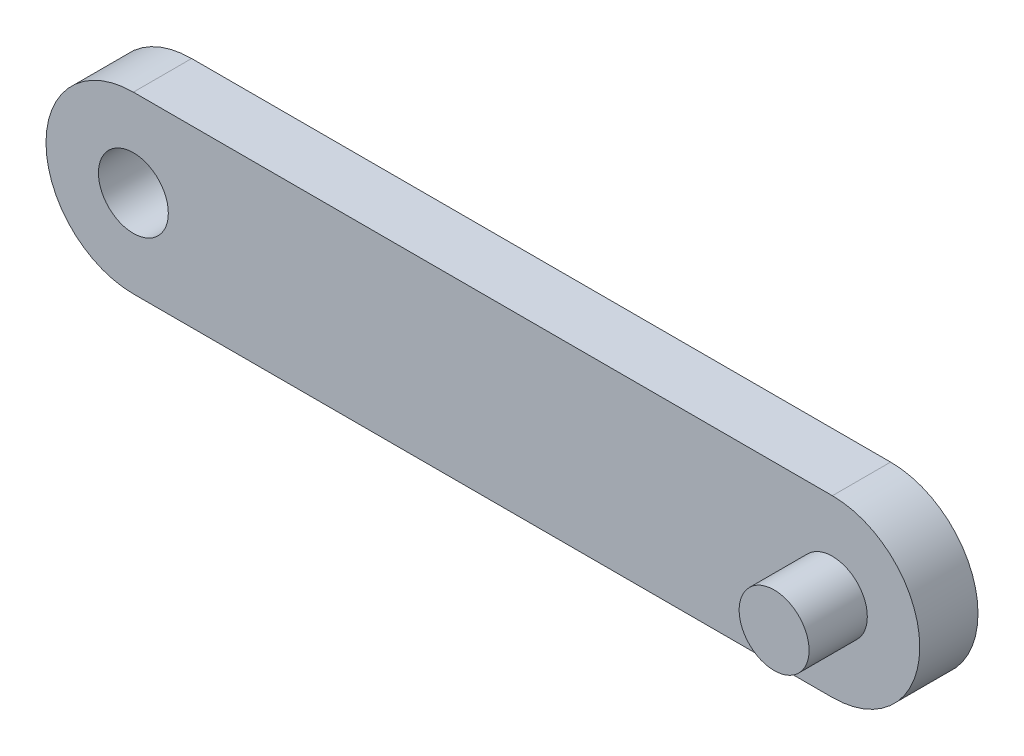
from build123d import *

# Parameters (mm, degrees)
CROQUIS1_R              = 6
SALIENTE_EXTRUIR1_DEPTH = 10
CROQUIS2_R              = 6
SALIENTE_EXTRUIR2_DEPTH = 10


with BuildPart() as part:
    # Croquis1 → Saliente-Extruir1 (new body)
    with BuildSketch(Plane.XY):
        with BuildLine():
            Line((0, 15), (120, 15))
            ThreePointArc((120, 15), (135, 0), (120, -15))
            Line((120, -15), (0, -15))
            ThreePointArc((0, -15), (-15, 0), (0, 15))
        make_face()
        Circle(CROQUIS1_R, mode=Mode.SUBTRACT)
    extrude(amount=SALIENTE_EXTRUIR1_DEPTH)

    # Croquis2 → Saliente-Extruir2 (add)
    with BuildSketch(Plane.XY.offset(10)):
        with Locations((120, 0)):
            Circle(CROQUIS2_R)
    extrude(amount=SALIENTE_EXTRUIR2_DEPTH)


solid = part.part
